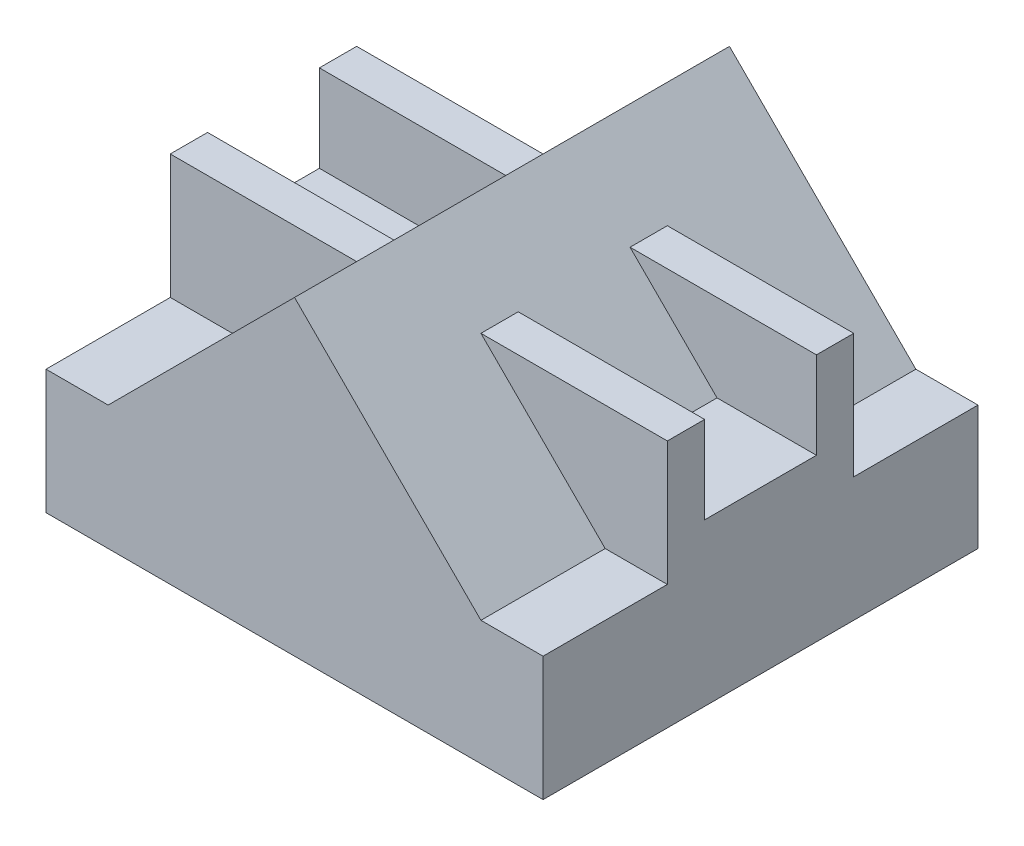
from build123d import *

# Parameters (mm, degrees)
SKETCH1_W           = 200
SKETCH1_H           = 125
BOSS_EXTRUDE1_DEPTH = 175
CUT_EXTRUDE1_DEPTH  = 212.024287702
CUT_EXTRUDE2_DEPTH  = 212.024287702
BOSS_EXTRUDE2_DEPTH = 125
CUT_EXTRUDE3_DEPTH  = 110
BOSS_EXTRUDE3_DEPTH = 65
CUT_EXTRUDE4_DEPTH  = 50
SKETCH3_W           = 200
SKETCH3_H           = 45
BOSS_EXTRUDE4_DEPTH = 15


with BuildPart() as part:
    # Sketch1 → Boss-Extrude1 (new body)
    with BuildSketch(Plane.XY):
        Rectangle(SKETCH1_W, SKETCH1_H)
    extrude(amount=BOSS_EXTRUDE1_DEPTH)

    # Sketch1_3 → Cut-Extrude1 (cut, through all)
    with BuildSketch(Plane.XY):
        Polygon((-100, 62.5), (-100, 37.5), (-25, 37.5), (0, 62.5), align=None)
        Polygon((0, 62.5), (25, 37.5), (100, 37.5), (100, 62.5), align=None)
    extrude(amount=CUT_EXTRUDE1_DEPTH, mode=Mode.SUBTRACT)

    # Sketch1_4 → Cut-Extrude2 (cut, through all)
    with BuildSketch(Plane.XY):
        Polygon((-100, 37.5), (-100, -12.5), (-75, -12.5), (-25, 37.5), align=None)
        Polygon((25, 37.5), (75, -12.5), (100, -12.5), (100, 37.5), align=None)
    extrude(amount=CUT_EXTRUDE2_DEPTH, mode=Mode.SUBTRACT)

    # Sketch1_5 → Boss-Extrude2 (add)
    with BuildSketch(Plane.XY):
        Polygon((-100, 37.5), (-100, -12.5), (-75, -12.5), (-25, 37.5), align=None)
        Polygon((25, 37.5), (75, -12.5), (100, -12.5), (100, 37.5), align=None)
    extrude(amount=BOSS_EXTRUDE2_DEPTH)

    # Sketch1_6 → Cut-Extrude3 (cut)
    with BuildSketch(Plane.XY):
        Polygon((-100, 37.5), (-100, -12.5), (-75, -12.5), (-25, 37.5), align=None)
        Polygon((25, 37.5), (75, -12.5), (100, -12.5), (100, 37.5), align=None)
    extrude(amount=CUT_EXTRUDE3_DEPTH, mode=Mode.SUBTRACT)

    # Sketch1_9 → Boss-Extrude3 (add)
    with BuildSketch(Plane.XY):
        Polygon((-100, 37.5), (-100, -12.5), (-75, -12.5), (-25, 37.5), align=None)
        Polygon((25, 37.5), (75, -12.5), (100, -12.5), (100, 37.5), align=None)
    extrude(amount=BOSS_EXTRUDE3_DEPTH)

    # Sketch1_10 → Cut-Extrude4 (cut)
    with BuildSketch(Plane.XY):
        Polygon((-100, 37.5), (-100, -12.5), (-75, -12.5), (-25, 37.5), align=None)
        Polygon((25, 37.5), (75, -12.5), (100, -12.5), (100, 37.5), align=None)
    extrude(amount=CUT_EXTRUDE4_DEPTH, mode=Mode.SUBTRACT)

    # Sketch3 → Boss-Extrude4 (add)
    with BuildSketch(Plane(origin=(0, -12.5, 0), x_dir=(1, 0, 0), z_dir=(0, 1, 0))):
        with Locations((0, -87.5)):
            Rectangle(SKETCH3_W, SKETCH3_H)
    extrude(amount=BOSS_EXTRUDE4_DEPTH)


solid = part.part
